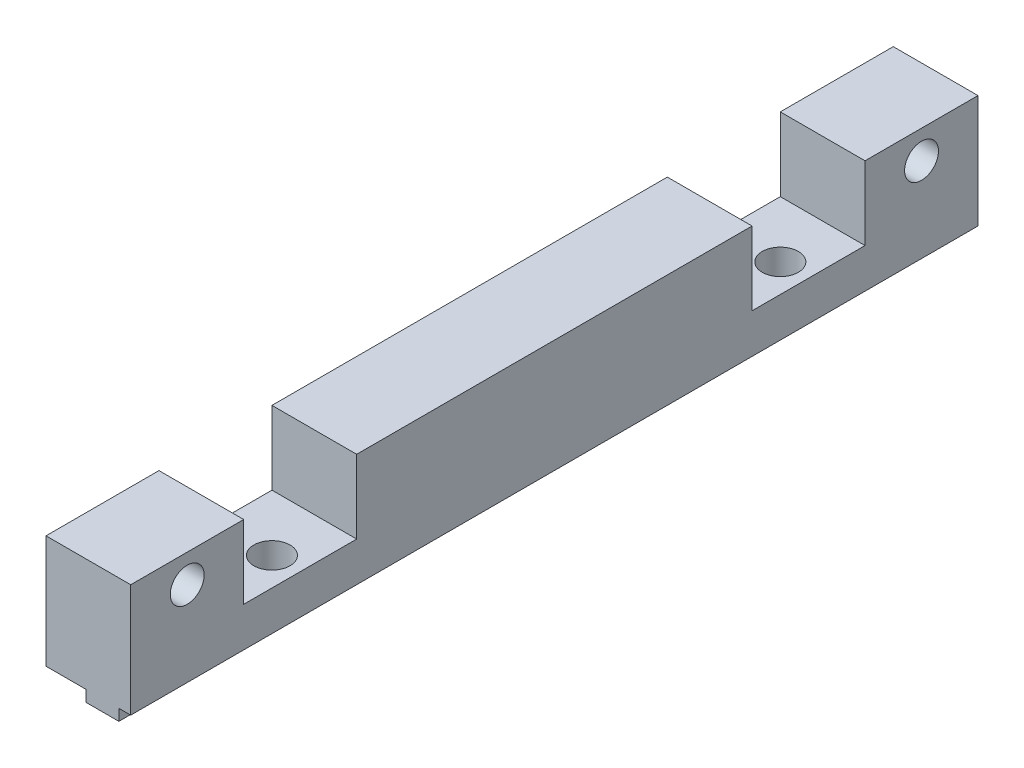
from build123d import *

# Parameters (mm, degrees)
MAIN_DEPTH              = 75
ESQUISSE2_R             = 1.5
ENL_V_MAT_EXTRU_1_DEPTH = 8.5
ESQUISSE3_W             = 10
ESQUISSE3_H             = 6.5
ENL_V_MAT_EXTRU_2_DEPTH = 8.5
ESQUISSE4_R             = 1.6
ENL_V_MAT_EXTRU_3_DEPTH = 12


with BuildPart() as part:
    # Esquisse1 → Main (new body)
    with BuildSketch(Plane.XY):
        Polygon((0, 10), (7.5, 10), (7.5, 0), (6.45, 0), (6.45, -1), (3.55, -1), (3.55, 0), (0, 0), align=None)
    extrude(amount=MAIN_DEPTH)

    # Esquisse2 → Enlèv. mat.-Extru.1 (cut, through all)
    with BuildSketch(Plane(origin=(7.5, 0, 0), x_dir=(0, 0, -1), z_dir=(1, 0, 0))):
        with Locations((-5, 7.5)):
            Circle(ESQUISSE2_R)
        with Locations((-70, 7.5)):
            Circle(ESQUISSE2_R)
    extrude(amount=-ENL_V_MAT_EXTRU_1_DEPTH, mode=Mode.SUBTRACT)

    # Esquisse3 → Enlèv. mat.-Extru.2 (cut, through all)
    with BuildSketch(Plane(origin=(7.5, 0, 0), x_dir=(0, 0, -1), z_dir=(1, 0, 0))):
        with Locations((-60, 6.75)):
            Rectangle(ESQUISSE3_W, ESQUISSE3_H)
        with Locations((-15, 6.75)):
            Rectangle(ESQUISSE3_W, ESQUISSE3_H)
    extrude(amount=-ENL_V_MAT_EXTRU_2_DEPTH, mode=Mode.SUBTRACT)

    # Esquisse4 → Enlèv. mat.-Extru.3 (cut, through all)
    with BuildSketch(Plane(origin=(0, -1, 0), x_dir=(-1, 0, 0), z_dir=(0, -1, 0))):
        with Locations((-5, -60)):
            Circle(ESQUISSE4_R)
        with Locations((-5, -15)):
            Circle(ESQUISSE4_R)
    extrude(amount=-ENL_V_MAT_EXTRU_3_DEPTH, mode=Mode.SUBTRACT)


solid = part.part
